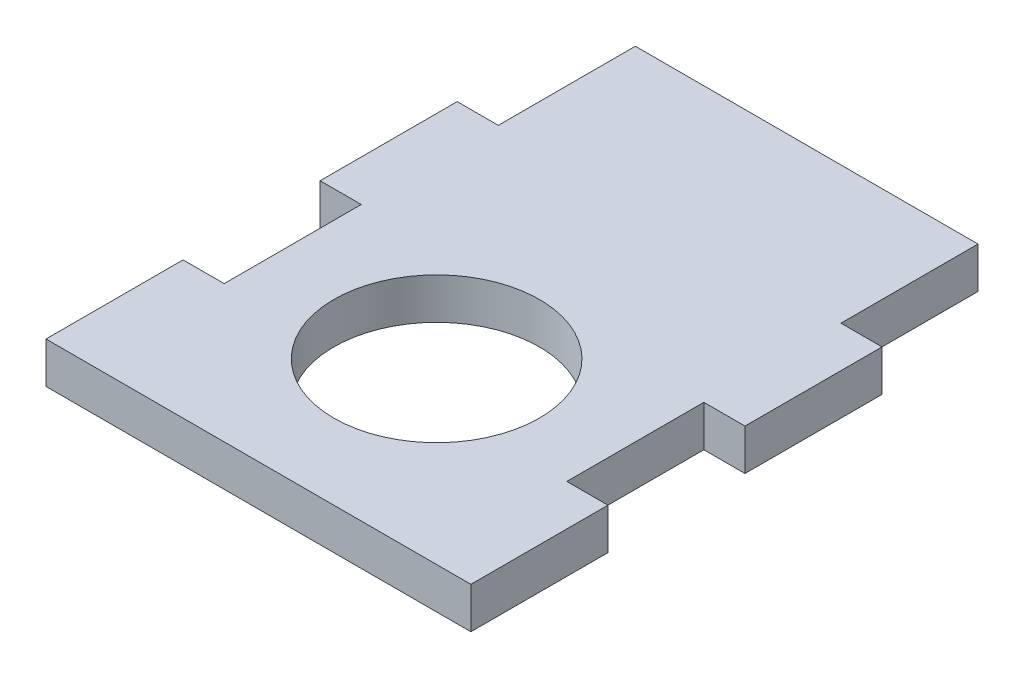
from build123d import *

# Parameters (mm, degrees)
SKETCH1_W           = 25
SKETCH1_H           = 40
BOSS_EXTRUDE1_DEPTH = 3
SKETCH2_W           = 3
SKETCH2_H           = 10
BOSS_EXTRUDE2_DEPTH = 3
SKETCH3_R           = 7.5
CUT_EXTRUDE1_DEPTH  = 4


with BuildPart() as part:
    # Sketch1 → Boss-Extrude1 (new body)
    with BuildSketch(Plane(origin=(0, 0, 0), x_dir=(1, 0, 0), z_dir=(0, 1, 0))):
        Rectangle(SKETCH1_W, SKETCH1_H)
    extrude(amount=BOSS_EXTRUDE1_DEPTH)

    # Sketch2 → Boss-Extrude2 (add)
    with BuildSketch(Plane(origin=(0, 3, 0), x_dir=(1, 0, 0), z_dir=(0, 1, 0))):
        with Locations((14, -15)):
            Rectangle(SKETCH2_W, SKETCH2_H)
        with Locations((14, 5)):
            Rectangle(SKETCH2_W, SKETCH2_H)
        with Locations((-14, -15)):
            Rectangle(SKETCH2_W, SKETCH2_H)
        with Locations((-14, 5)):
            Rectangle(SKETCH2_W, SKETCH2_H)
    extrude(amount=-BOSS_EXTRUDE2_DEPTH)

    # Sketch3 → Cut-Extrude1 (cut, through all)
    with BuildSketch(Plane(origin=(0, 3, 0), x_dir=(1, 0, 0), z_dir=(0, 1, 0))):
        with Locations((0, -7)):
            Circle(SKETCH3_R)
    extrude(amount=-CUT_EXTRUDE1_DEPTH, mode=Mode.SUBTRACT)


solid = part.part
